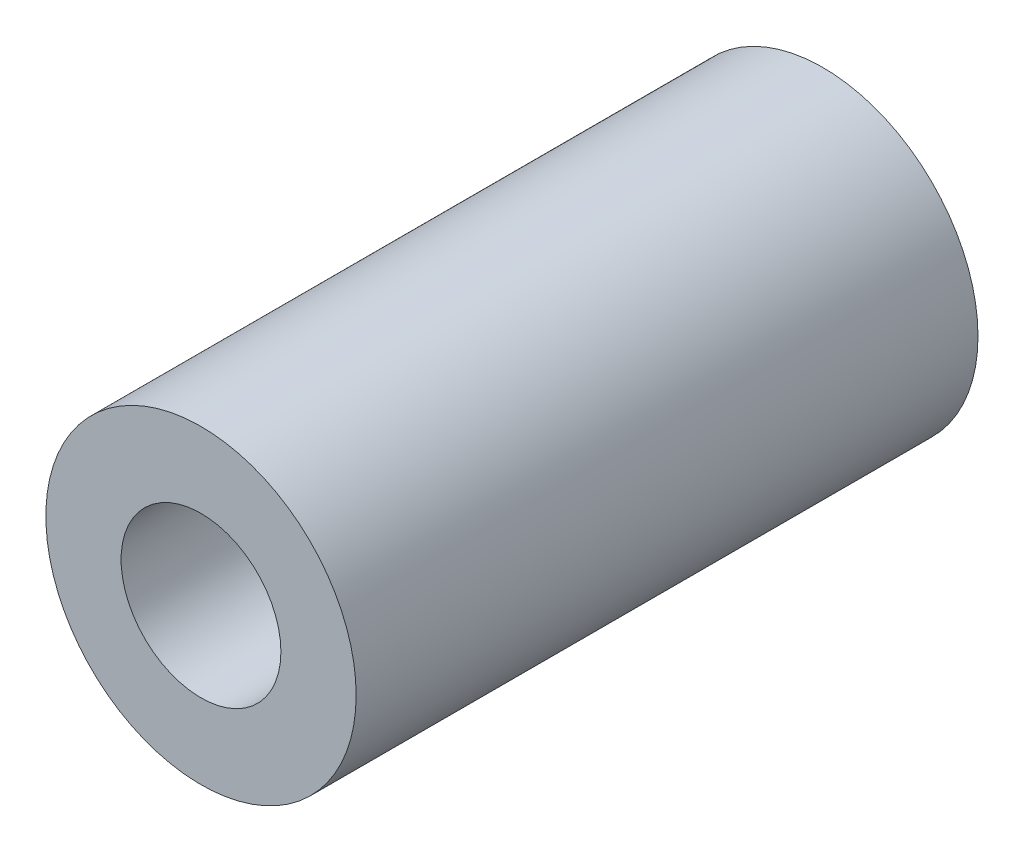
from build123d import *

# Parameters (mm, degrees)
SKETCH1_R           = 6.3373
SKETCH1_R_2         = 3.2639
BOSS_EXTRUDE1_DEPTH = 25.4


with BuildPart() as part:
    # Sketch1 → Boss-Extrude1 (new body)
    with BuildSketch(Plane.XY):
        with Locations((59.194737463, -18.406694864)):
            Circle(SKETCH1_R)
        with Locations((59.194737463, -18.406694864)):
            Circle(SKETCH1_R_2, mode=Mode.SUBTRACT)
    extrude(amount=BOSS_EXTRUDE1_DEPTH)


solid = part.part
